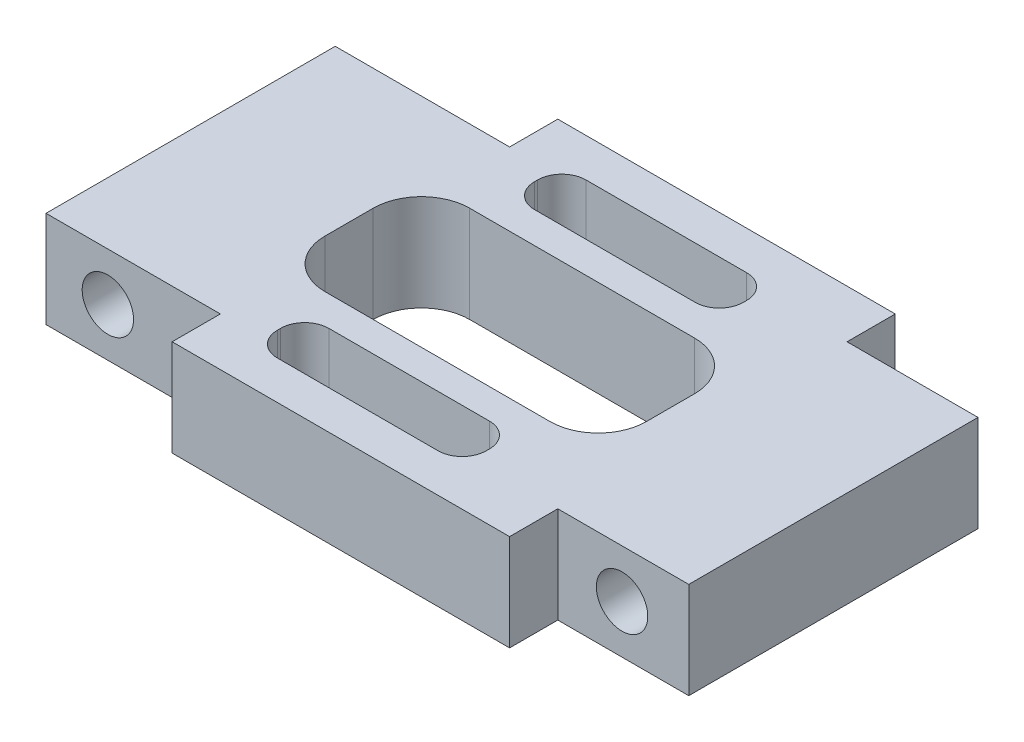
from build123d import *

# Parameters (mm, degrees)
EXTRUDE_1_DEPTH     = 6
SKETCH_2_R          = 1.6
CUT_EXTRUDE_1_DEPTH = 22


with BuildPart() as part:
    # Эскиз1 → Бобышка-Вытянуть1 (new body)
    with BuildSketch(Plane(origin=(0, 0, 0), x_dir=(1, 0, 0), z_dir=(0, 1, 0))):
        Polygon((-9.65, 9), (-9.65, 12), (11.35, 12), (11.35, 9), (19.5, 9), (19.5, -9), (11.35, -9), (11.35, -12), (-9.65, -12), (-9.65, -9), (-20.5, -9), (-20.5, 9), align=None)
        with BuildLine():
            Line((6.406364979, -4.542135759), (-7.593635021, -4.542135759))
            ThreePointArc((-7.593635021, -4.542135759), (-9.714955364, -3.663456103), (-10.593635021, -1.542135759))
            Line((-10.593635021, -1.542135759), (-10.593635021, 1.457864241))
            ThreePointArc((-10.593635021, 1.457864241), (-9.714955364, 3.579184584), (-7.593635021, 4.457864241))
            Line((-7.593635021, 4.457864241), (6.406364979, 4.457864241))
            ThreePointArc((6.406364979, 4.457864241), (8.527685323, 3.579184584), (9.406364979, 1.457864241))
            Line((9.406364979, 1.457864241), (9.406364979, -1.542135759))
            ThreePointArc((9.406364979, -1.542135759), (8.527685323, -3.663456103), (6.406364979, -4.542135759))
        make_face(mode=Mode.SUBTRACT)
        with BuildLine():
            Line((4.5, 6.4), (-5.5, 6.4))
            ThreePointArc((-5.5, 6.4), (-6.560660172, 6.839339828), (-7, 7.9))
            Line((-7, 7.9), (-7, 8.1))
            ThreePointArc((-7, 8.1), (-6.560660172, 9.160660172), (-5.5, 9.6))
            Line((-5.5, 9.6), (4.5, 9.6))
            ThreePointArc((4.5, 9.6), (5.560660172, 9.160660172), (6, 8.1))
            Line((6, 8.1), (6, 7.9))
            ThreePointArc((6, 7.9), (5.560660172, 6.839339828), (4.5, 6.4))
        make_face(mode=Mode.SUBTRACT)
        with BuildLine():
            Line((4.5, -9.6), (-5.5, -9.6))
            ThreePointArc((-5.5, -9.6), (-6.560660172, -9.160660172), (-7, -8.1))
            Line((-7, -8.1), (-7, -7.9))
            ThreePointArc((-7, -7.9), (-6.560660172, -6.839339828), (-5.5, -6.4))
            Line((-5.5, -6.4), (4.5, -6.4))
            ThreePointArc((4.5, -6.4), (5.560660172, -6.839339828), (6, -7.9))
            Line((6, -7.9), (6, -8.1))
            ThreePointArc((6, -8.1), (5.560660172, -9.160660172), (4.5, -9.6))
        make_face(mode=Mode.SUBTRACT)
    extrude(amount=EXTRUDE_1_DEPTH)

    # Эскиз2 → Вырез-Вытянуть1 (cut, through all)
    with BuildSketch(Plane(origin=(0, 0, -9), x_dir=(-1, 0, 0), z_dir=(0, 0, -1))):
        with Locations((-15.35, 3)):
            Circle(SKETCH_2_R)
        with Locations((16.65, 3)):
            Circle(SKETCH_2_R)
    extrude(amount=-CUT_EXTRUDE_1_DEPTH, mode=Mode.SUBTRACT)


solid = part.part
